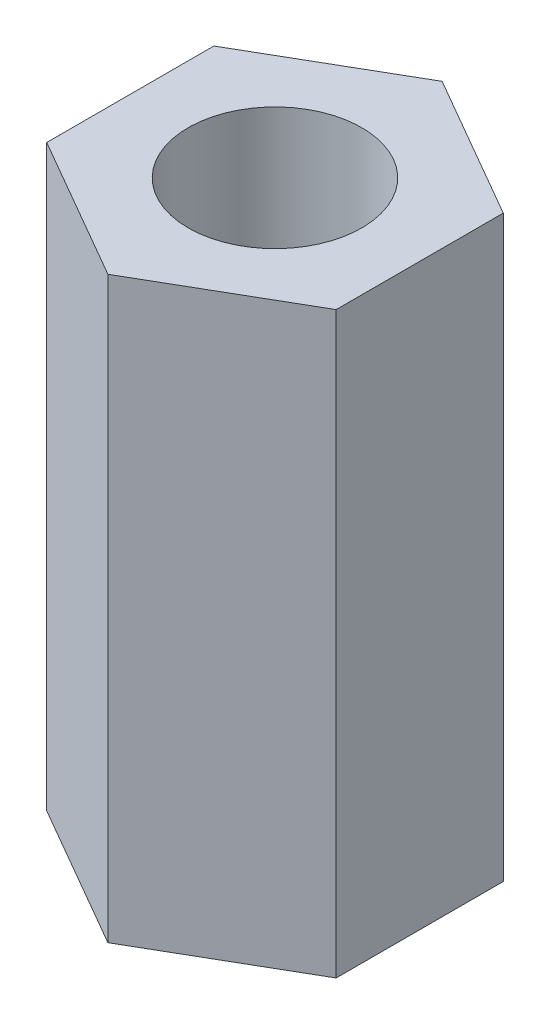
from build123d import *

# Parameters (mm, degrees)
SKETCH1_R           = 1.5
BOSS_EXTRUDE1_DEPTH = 10


with BuildPart() as part:
    # Sketch1 → Boss-Extrude1 (new body)
    with BuildSketch(Plane(origin=(0, 0, 0), x_dir=(1, 0, 0), z_dir=(0, 1, 0))):
        Polygon((-34.951809206, 17.093781707), (-37.451809206, 15.650406034), (-37.451809206, 12.763654688), (-34.951809206, 11.320279015), (-32.451809206, 12.763654688), (-32.451809206, 15.650406034), align=None)
        with Locations((-34.951809206, 14.207030361)):
            Circle(SKETCH1_R, mode=Mode.SUBTRACT)
    extrude(amount=BOSS_EXTRUDE1_DEPTH)


solid = part.part
